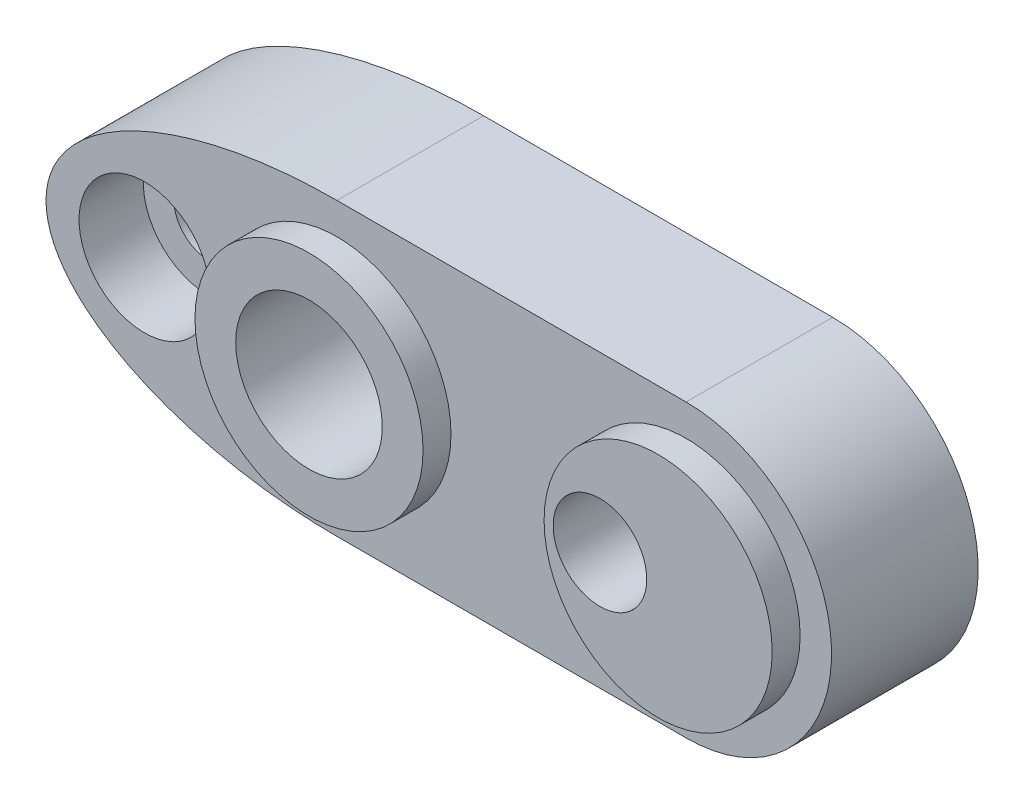
from build123d import *

# Parameters (mm, degrees)
BOSS_EXTRUDE1_DEPTH                            = 9.525
SKETCH2_OUTSIDE_W                              = 54.201
SKETCH2_OUTSIDE_H                              = 27.214
SKETCH2_OUTSIDE_R                              = 6.223
CUT_EXTRUDE1_DEPTH                             = 1.524
SKETCH3_R                                      = 4
CUT_EXTRUDE2_DEPTH                             = 10.525
CBORE_FOR_6_SOCKET_HEAD_CAP_SCREW1_D           = 3.7973
CBORE_FOR_6_SOCKET_HEAD_CAP_SCREW1_CBORE_D     = 7.14502
CBORE_FOR_6_SOCKET_HEAD_CAP_SCREW1_CBORE_DEPTH = 3.5052
F_1_4_20_TAPPED_HOLE1_D                        = 5.1054


with BuildPart() as part:
    # Sketch1 → Boss-Extrude1 (new body)
    with BuildSketch(Plane.XY):
        with BuildLine():
            Line((0, 7.9375), (19.05, 7.9375))
            ThreePointArc((19.05, 7.9375), (26.9875, 0), (19.05, -7.9375))
            Line((19.05, -7.9375), (0, -7.9375))
            add(Edge.make_bspline(
                [(0, 7.9375), (-15.875, 7.9375), (-15.875, 0), (-15.875, -7.9375), (0, -7.9375)],
                knots=[4.71238898, 4.71238898, 4.71238898, 6.283185307, 6.283185307, 7.853981634, 7.853981634, 7.853981634], degree=2, weights=[1, 0.707106781, 1, 0.707106781, 1]))
        make_face()
    extrude(amount=-BOSS_EXTRUDE1_DEPTH)

    # Sketch2 outside → Cut-Extrude1 (cut)
    with BuildSketch(Plane.XY):
        with Locations((5.5565, 0)):
            Rectangle(SKETCH2_OUTSIDE_W, SKETCH2_OUTSIDE_H)
        Circle(SKETCH2_OUTSIDE_R, mode=Mode.SUBTRACT)
        with Locations((19.05, 0)):
            Circle(SKETCH2_OUTSIDE_R, mode=Mode.SUBTRACT)
    extrude(amount=-CUT_EXTRUDE1_DEPTH, mode=Mode.SUBTRACT)

    # Sketch3 → Cut-Extrude2 (cut, through all)
    with BuildSketch(Plane(origin=(0, 0, -9.525), x_dir=(-1, 0, 0), z_dir=(0, 0, -1))):
        Circle(SKETCH3_R)
    extrude(amount=-CUT_EXTRUDE2_DEPTH, mode=Mode.SUBTRACT)

    # CBORE for #6 Socket Head Cap Screw1 (through all)
    with Locations(Plane.XY.offset(-1.524)):
        with Locations((-10.5, 0)):
            CounterBoreHole(CBORE_FOR_6_SOCKET_HEAD_CAP_SCREW1_D / 2, CBORE_FOR_6_SOCKET_HEAD_CAP_SCREW1_CBORE_D / 2, CBORE_FOR_6_SOCKET_HEAD_CAP_SCREW1_CBORE_DEPTH)

    # 1/4-20 Tapped Hole1 (through all)
    with Locations(Plane.XY):
        with Locations((15.875, 0)):
            Hole(F_1_4_20_TAPPED_HOLE1_D / 2)


solid = part.part
